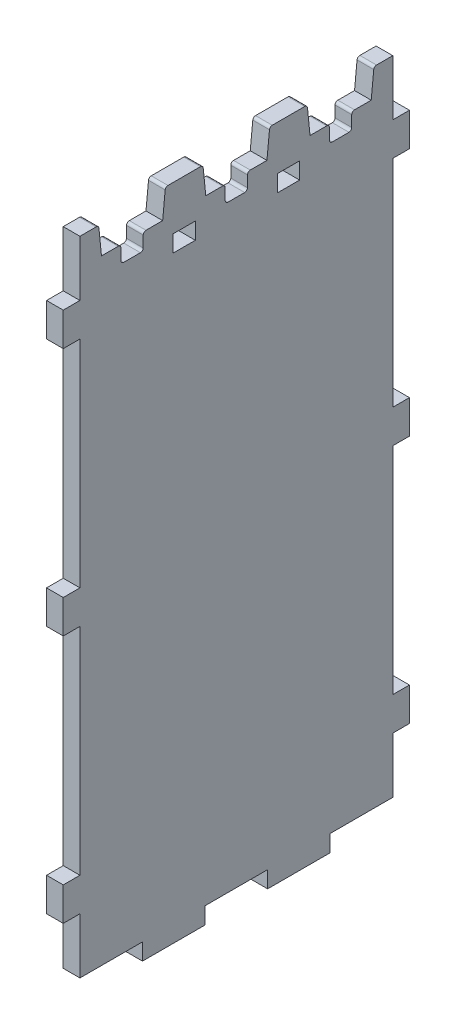
from build123d import *

# Parameters (mm, degrees)
BOSS_EXTRUDE2_DEPTH    = 6
FILLET1_R              = 1
LPATTERN1_COUNT        = 3
LPATTERN1_PITCH        = 37.5
FILLET1_OF_LPATTERN1_R = 1
SKETCH3_W              = 6
SKETCH3_H              = 12
BOSS_EXTRUDE3_DEPTH    = 6
SKETCH4_W              = 8
SKETCH4_H              = 6
CUT_EXTRUDE2_DEPTH     = 7
LPATTERN2_COUNT        = 2
LPATTERN2_PITCH        = 37.5
BOSS_EXTRUDE4_START    = -112.5
SKETCH3_2_W            = 6
SKETCH3_2_H            = 12
BOSS_EXTRUDE4_DEPTH    = 6
SKETCH5_W              = 6
SKETCH5_H              = 22.5
BOSS_EXTRUDE5_DEPTH    = 6


with BuildPart() as part:
    # Sketch2 → Boss-Extrude2 (new body)
    with BuildSketch(Plane(origin=(0, 0, 0), x_dir=(0, 0, -1), z_dir=(1, 0, 0))):
        Polygon((-18.75, 123.5), (-18.75, 107.5), (-18.75, -107.5), (18.75, -107.5), (18.75, 107.5), (18.75, 123.5), (12, 123.5), (11, 113.5), (4, 113.5), (4, 107.5), (-4, 107.5), (-4, 113.5), (-11, 113.5), (-12, 123.5), align=None)
    boss_extrude2 = extrude(amount=BOSS_EXTRUDE2_DEPTH)

    # Fillet1
    fillet1_edges = [part.edges().sort_by_distance(p)[0] for p in [
        (3, 113.5, -4),
        (3, 123.5, -12),
        (3, 123.5, 12),
        (3, 113.5, 4),
        (3, 107.5, 4),
        (3, 107.5, -4),
    ]]
    fillet(fillet1_edges, radius=FILLET1_R)

    # LPattern1: Boss-Extrude2 ×3
    with Locations(*[(0, 0, i * LPATTERN1_PITCH) for i in range(1, LPATTERN1_COUNT)]):
        add(boss_extrude2)

    # Fillet1 of LPattern1
    fillet1_of_lpattern1_edges = [part.edges().sort_by_distance(p)[0] for p in [
        (3, 113.5, 33.5),
        (3, 123.5, 25.5),
        (3, 123.5, 49.5),
        (3, 113.5, 41.5),
        (3, 107.5, 41.5),
        (3, 107.5, 33.5),
        (3, 113.5, 71),
        (3, 123.5, 63),
        (3, 123.5, 87),
        (3, 113.5, 79),
        (3, 107.5, 79),
        (3, 107.5, 71),
    ]]
    fillet(fillet1_of_lpattern1_edges, radius=FILLET1_OF_LPATTERN1_R)

    # Sketch3 → Boss-Extrude3 (add)
    with BuildSketch(Plane(origin=(0, 0, -18.75), x_dir=(-1, 0, 0), z_dir=(0, 0, -1))):
        with Locations((-3, 97.5)):
            Rectangle(SKETCH3_W, SKETCH3_H)
        with Locations((-3, -81.5)):
            Rectangle(SKETCH3_W, SKETCH3_H)
        with Locations((-3, 8)):
            Rectangle(SKETCH3_W, SKETCH3_H)
    extrude(amount=BOSS_EXTRUDE3_DEPTH)

    # Sketch4 → Cut-Extrude2 (cut, through all)
    with BuildSketch(Plane(origin=(0, 0, 0), x_dir=(0, 0, -1), z_dir=(1, 0, 0))):
        with Locations((-18.75, 104.5)):
            Rectangle(SKETCH4_W, SKETCH4_H)
    cut_extrude2 = extrude(amount=CUT_EXTRUDE2_DEPTH, mode=Mode.SUBTRACT)

    # LPattern2: Cut-Extrude2 ×2
    with Locations(*[(0, 0, i * LPATTERN2_PITCH) for i in range(1, LPATTERN2_COUNT)]):
        add(cut_extrude2, mode=Mode.SUBTRACT)

    # Sketch3_2 → Boss-Extrude4 (add)
    with BuildSketch(Plane(origin=(0, 0, -18.75), x_dir=(-1, 0, 0), z_dir=(0, 0, -1)).offset(BOSS_EXTRUDE4_START)):
        with Locations((-3, 97.5)):
            Rectangle(SKETCH3_2_W, SKETCH3_2_H)
        with Locations((-3, -81.5)):
            Rectangle(SKETCH3_2_W, SKETCH3_2_H)
        with Locations((-3, 8)):
            Rectangle(SKETCH3_2_W, SKETCH3_2_H)
    extrude(amount=-BOSS_EXTRUDE4_DEPTH)

    # Sketch5 → Boss-Extrude5 (add)
    with BuildSketch(Plane.XZ.offset(107.5)):
        with Locations((3, 15)):
            Rectangle(SKETCH5_W, SKETCH5_H)
        with Locations((3, 60)):
            Rectangle(SKETCH5_W, SKETCH5_H)
    extrude(amount=BOSS_EXTRUDE5_DEPTH)


solid = part.part
